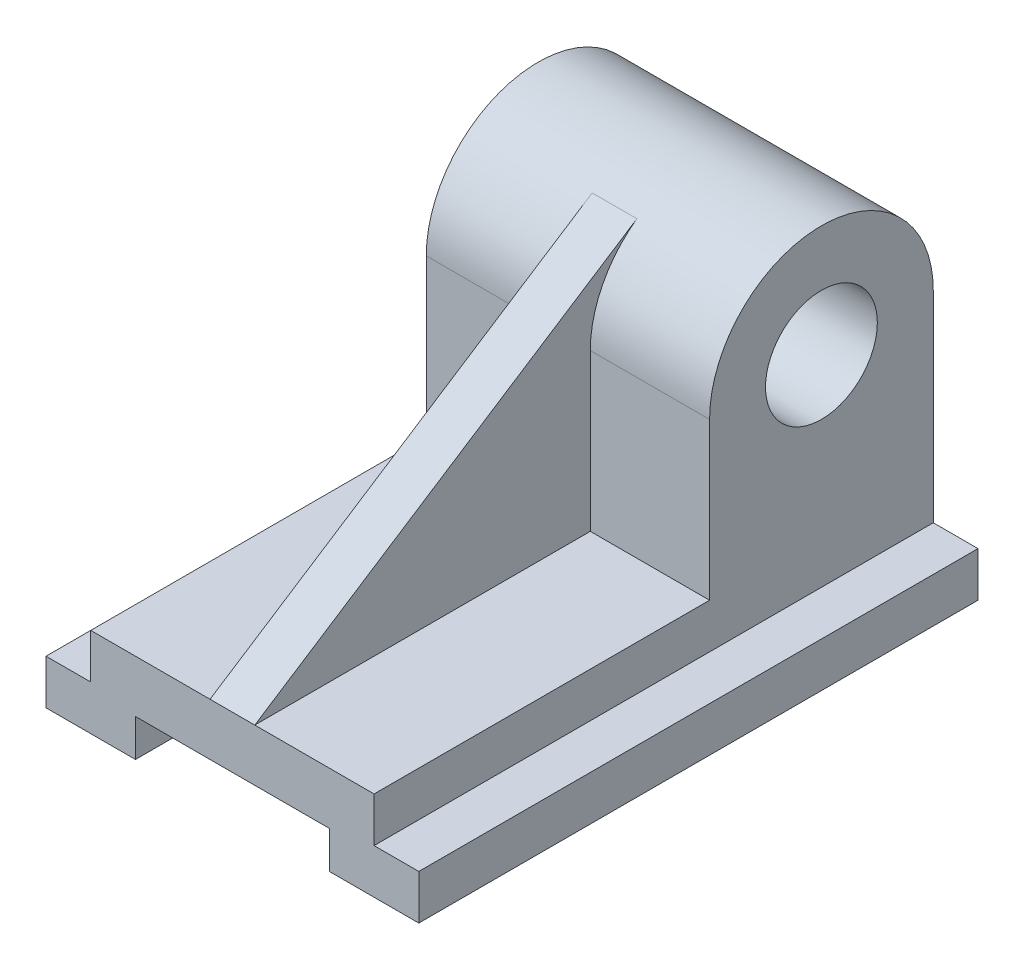
from build123d import *

# Parameters (mm, degrees)
BOSS_EXTRUDE1_DEPTH = 150
SKETCH4_R           = 15
BOSS_EXTRUDE2_DEPTH = 38
RIB1_REACH          = 181.042
SKETCH5_WALL_W      = 482.19756146
SKETCH5_WALL_H      = 12


with BuildPart() as part:
    # Sketch1 → Boss-Extrude1 (new body)
    with BuildSketch(Plane.XY):
        Polygon((-50, 0), (-38, 0), (-38, 12), (38, 12), (38, 0), (50, 0), (50, -12), (26, -12), (26, -2), (-26, -2), (-26, -12), (-50, -12), align=None)
    extrude(amount=BOSS_EXTRUDE1_DEPTH)

    # Sketch4 → Boss-Extrude2 (add, symmetric)
    with BuildSketch(Plane(origin=(0, 0, 0), x_dir=(0, 0, -1), z_dir=(1, 0, 0))):
        with BuildLine():
            Line((0, 12), (0, 54))
            ThreePointArc((0, 54), (-30, 84), (-60, 54))
            Line((-60, 54), (-60, 12))
            Line((-60, 12), (0, 12))
        make_face()
        with Locations((-30, 54)):
            Circle(SKETCH4_R, mode=Mode.SUBTRACT)
    extrude(amount=BOSS_EXTRUDE2_DEPTH, both=True)

    # Sketch5 wall → Rib1 (add, up to next)
    with BuildSketch(Plane(origin=(0, 45.18462462, 98.748424022), x_dir=(0, 0.54350338987, -0.839406972332), z_dir=(0, 0.839406972332, 0.54350338987)), mode=Mode.PRIVATE) as rib1_sk1:
        Rectangle(SKETCH5_WALL_W, SKETCH5_WALL_H)
    rib1_tool1 = extrude(rib1_sk1.sketch, amount=-RIB1_REACH, mode=Mode.PRIVATE) - part.part
    add(rib1_tool1.solids().sort_by_distance((0, 45.18462462, 98.748424022))[0])


solid = part.part
